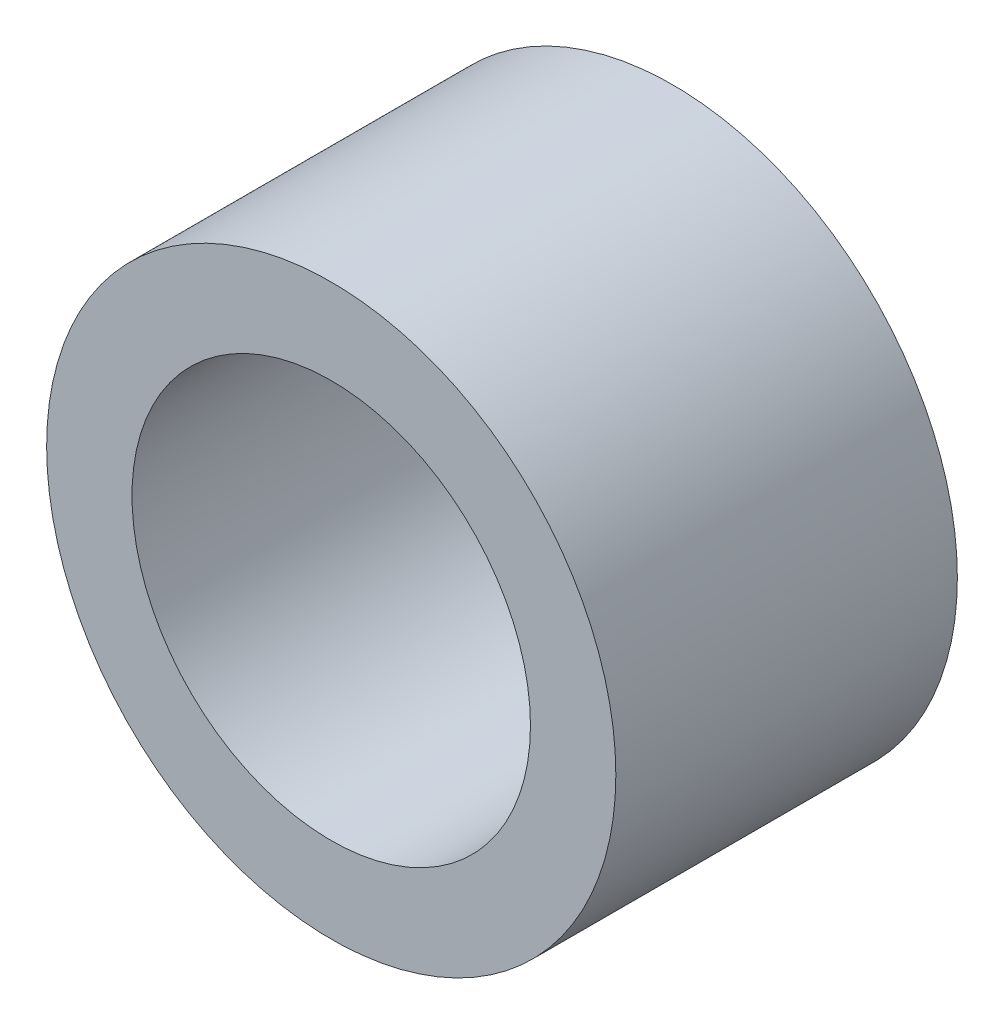
from build123d import *

# Parameters (mm, degrees)
ESQUISSE1_R        = 2.5
ESQUISSE1_R_2      = 1.75
BOSS_EXTRU_1_DEPTH = 3


with BuildPart() as part:
    # Esquisse1 → Boss.-Extru.1 (new body)
    with BuildSketch(Plane.XY):
        Circle(ESQUISSE1_R)
        Circle(ESQUISSE1_R_2, mode=Mode.SUBTRACT)
    extrude(amount=BOSS_EXTRU_1_DEPTH)


solid = part.part
